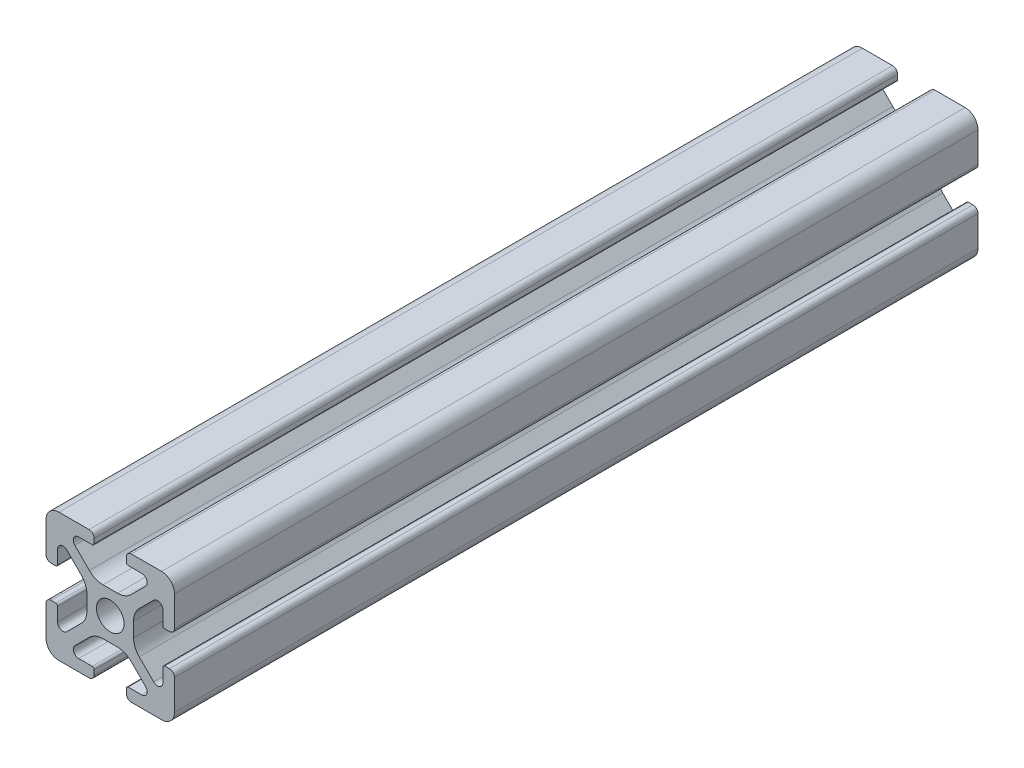
from build123d import *

# Parameters (mm, degrees)
SKETCH1_R           = 2.1463
BOSS_EXTRUDE1_DEPTH = 62.5


with BuildPart() as part:
    # Sketch1 → Boss-Extrude1 (new body, symmetric)
    with BuildSketch(Plane.XY):
        with BuildLine():
            Line((-9.9949, 7.9883), (-9.9949, 3.2893))
            ThreePointArc((-9.9949, 3.2893), (-9.76427588, 2.73252412), (-9.2075, 2.5019))
            Line((-9.2075, 2.5019), (-8.4963, 2.5019))
            ThreePointArc((-8.4963, 2.5019), (-8.280773853, 2.591173853), (-8.1915, 2.8067))
            Line((-8.1915, 2.8067), (-8.1915, 4.9149))
            ThreePointArc((-8.1915, 4.9149), (-7.674065253, 5.689295824), (-6.760603096, 5.507596904))
            Line((-6.760603096, 5.507596904), (-4.505765747, 3.252759555))
            ThreePointArc((-4.505765747, 3.252759555), (-3.856054457, 2.280397894), (-3.627906192, 1.133419111))
            Line((-3.627906192, 1.133419111), (-3.627906192, -1.133419111))
            ThreePointArc((-3.627906192, -1.133419111), (-3.856054457, -2.280397894), (-4.505765747, -3.252759555))
            Line((-4.505765747, -3.252759555), (-6.760603096, -5.507596904))
            ThreePointArc((-6.760603096, -5.507596904), (-7.674065253, -5.689295824), (-8.1915, -4.9149))
            Line((-8.1915, -4.9149), (-8.1915, -2.8067))
            ThreePointArc((-8.1915, -2.8067), (-8.280773853, -2.591173853), (-8.4963, -2.5019))
            Line((-8.4963, -2.5019), (-9.2075, -2.5019))
            ThreePointArc((-9.2075, -2.5019), (-9.76427588, -2.73252412), (-9.9949, -3.2893))
            Line((-9.9949, -3.2893), (-9.9949, -7.9883))
            ThreePointArc((-9.9949, -7.9883), (-9.407180467, -9.407180467), (-7.9883, -9.9949))
            Line((-7.9883, -9.9949), (-3.2893, -9.9949))
            ThreePointArc((-3.2893, -9.9949), (-2.73252412, -9.76427588), (-2.5019, -9.2075))
            Line((-2.5019, -9.2075), (-2.5019, -8.4963))
            ThreePointArc((-2.5019, -8.4963), (-2.591173853, -8.280773853), (-2.8067, -8.1915))
            Line((-2.8067, -8.1915), (-4.9149, -8.1915))
            ThreePointArc((-4.9149, -8.1915), (-5.689295824, -7.674065253), (-5.507596904, -6.760603096))
            Line((-5.507596904, -6.760603096), (-3.252759555, -4.505765747))
            ThreePointArc((-3.252759555, -4.505765747), (-2.280397894, -3.856054457), (-1.133419111, -3.627906192))
            Line((-1.133419111, -3.627906192), (1.133419111, -3.627906192))
            ThreePointArc((1.133419111, -3.627906192), (2.280397894, -3.856054457), (3.252759555, -4.505765747))
            Line((3.252759555, -4.505765747), (5.507596904, -6.760603096))
            ThreePointArc((5.507596904, -6.760603096), (5.689295824, -7.674065253), (4.9149, -8.1915))
            Line((4.9149, -8.1915), (2.8067, -8.1915))
            ThreePointArc((2.8067, -8.1915), (2.591173853, -8.280773853), (2.5019, -8.4963))
            Line((2.5019, -8.4963), (2.5019, -9.2075))
            ThreePointArc((2.5019, -9.2075), (2.73252412, -9.76427588), (3.2893, -9.9949))
            Line((3.2893, -9.9949), (7.9883, -9.9949))
            ThreePointArc((7.9883, -9.9949), (9.407180467, -9.407180467), (9.9949, -7.9883))
            Line((9.9949, -7.9883), (9.9949, -3.2893))
            ThreePointArc((9.9949, -3.2893), (9.76427588, -2.73252412), (9.2075, -2.5019))
            Line((9.2075, -2.5019), (8.4963, -2.5019))
            ThreePointArc((8.4963, -2.5019), (8.280773853, -2.591173853), (8.1915, -2.8067))
            Line((8.1915, -2.8067), (8.1915, -4.9149))
            ThreePointArc((8.1915, -4.9149), (7.674065253, -5.689295824), (6.760603096, -5.507596904))
            Line((6.760603096, -5.507596904), (4.505765747, -3.252759555))
            ThreePointArc((4.505765747, -3.252759555), (3.856054457, -2.280397894), (3.627906192, -1.133419111))
            Line((3.627906192, -1.133419111), (3.627906192, 1.133419111))
            ThreePointArc((3.627906192, 1.133419111), (3.856054457, 2.280397894), (4.505765747, 3.252759555))
            Line((4.505765747, 3.252759555), (6.760603096, 5.507596904))
            ThreePointArc((6.760603096, 5.507596904), (7.674065253, 5.689295824), (8.1915, 4.9149))
            Line((8.1915, 4.9149), (8.1915, 2.8067))
            ThreePointArc((8.1915, 2.8067), (8.280773853, 2.591173853), (8.4963, 2.5019))
            Line((8.4963, 2.5019), (9.2075, 2.5019))
            ThreePointArc((9.2075, 2.5019), (9.76427588, 2.73252412), (9.9949, 3.2893))
            Line((9.9949, 3.2893), (9.9949, 7.9883))
            ThreePointArc((9.9949, 7.9883), (9.407180467, 9.407180467), (7.9883, 9.9949))
            Line((7.9883, 9.9949), (3.2893, 9.9949))
            ThreePointArc((3.2893, 9.9949), (2.73252412, 9.76427588), (2.5019, 9.2075))
            Line((2.5019, 9.2075), (2.5019, 8.4963))
            ThreePointArc((2.5019, 8.4963), (2.591173853, 8.280773853), (2.8067, 8.1915))
            Line((2.8067, 8.1915), (4.9149, 8.1915))
            ThreePointArc((4.9149, 8.1915), (5.689295824, 7.674065253), (5.507596904, 6.760603096))
            Line((5.507596904, 6.760603096), (3.252759555, 4.505765747))
            ThreePointArc((3.252759555, 4.505765747), (2.280397894, 3.856054457), (1.133419111, 3.627906192))
            Line((1.133419111, 3.627906192), (-1.133419111, 3.627906192))
            ThreePointArc((-1.133419111, 3.627906192), (-2.280397894, 3.856054457), (-3.252759555, 4.505765747))
            Line((-3.252759555, 4.505765747), (-5.507596904, 6.760603096))
            ThreePointArc((-5.507596904, 6.760603096), (-5.689295824, 7.674065253), (-4.9149, 8.1915))
            Line((-4.9149, 8.1915), (-2.8067, 8.1915))
            ThreePointArc((-2.8067, 8.1915), (-2.591173853, 8.280773853), (-2.5019, 8.4963))
            Line((-2.5019, 8.4963), (-2.5019, 9.2075))
            ThreePointArc((-2.5019, 9.2075), (-2.73252412, 9.76427588), (-3.2893, 9.9949))
            Line((-3.2893, 9.9949), (-7.9883, 9.9949))
            ThreePointArc((-7.9883, 9.9949), (-9.407180467, 9.407180467), (-9.9949, 7.9883))
        make_face()
        Circle(SKETCH1_R, mode=Mode.SUBTRACT)
    extrude(amount=BOSS_EXTRUDE1_DEPTH, both=True)


solid = part.part
